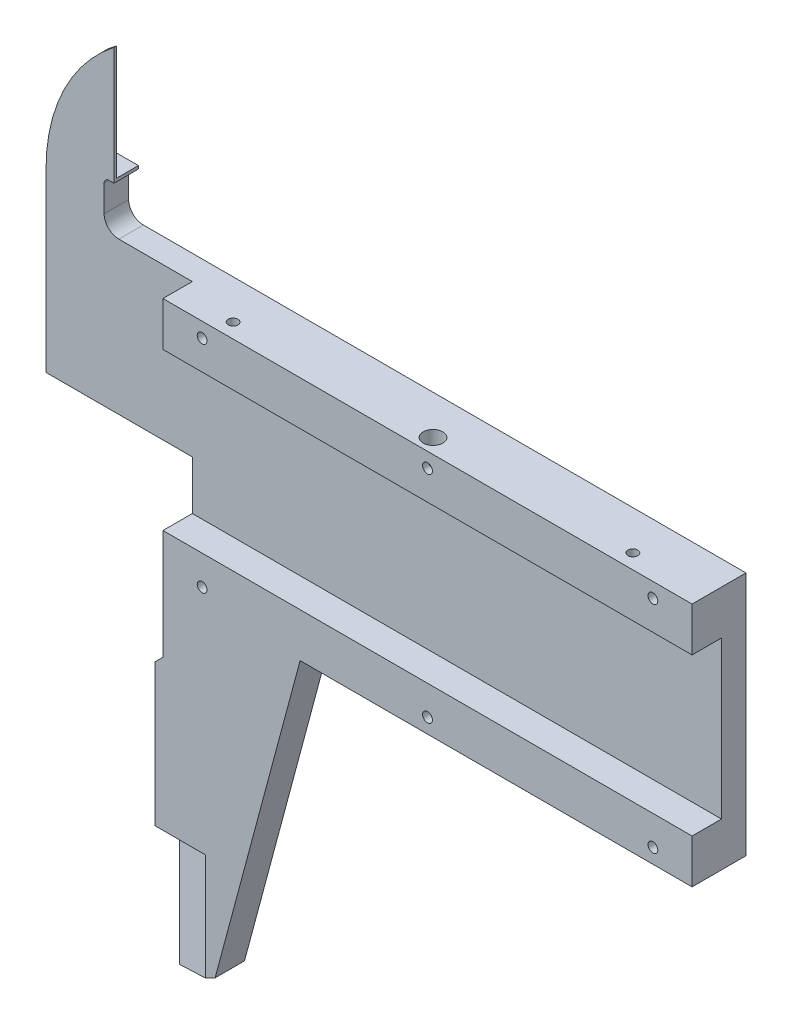
from build123d import *

# Parameters (mm, degrees)
BOSS_EXTRUDE1_DEPTH = 2.75
CUT_EXTRUDE1_DEPTH  = 3
SKETCH3_R           = 0.5
CUT_EXTRUDE2_DEPTH  = 1.25
CUT_EXTRUDE3_START  = 17.5
CUT_EXTRUDE3_DEPTH  = 12.5
SKETCH5_W           = 14.8
SKETCH5_H           = 2.5
CUT_EXTRUDE4_DEPTH  = 36.5
CUT_EXTRUDE5_START  = 35.5
CUT_EXTRUDE5_DEPTH  = 13.5
SKETCH7_R           = 0.5
CUT_EXTRUDE6_DEPTH  = 3
CUT_EXTRUDE7_REACH  = 62.5
SKETCH8_R           = 1


with BuildPart() as part:
    # Sketch1 → Boss-Extrude1 (new body, symmetric)
    with BuildSketch(Plane.XY):
        with BuildLine():
            Line((0, 0), (0, 12.5))
            Line((0, 12.5), (-61.5, 12.5))
            ThreePointArc((-61.5, 12.5), (-62.560660172, 12.939339828), (-63, 14))
            Line((-63, 14), (-63, 16.693487943))
            ThreePointArc((-63, 16.693487943), (-62.853553391, 17.047041334), (-62.5, 17.193487943))
            Line((-62.5, 17.193487943), (-62, 17.193487943))
            Line((-62, 17.193487943), (-62, 29.193487943))
            ThreePointArc((-62, 29.193487943), (-67.10498068, 22.897467949), (-68.93, 15))
            Line((-68.93, 15), (-68.93, -3))
            Line((-68.93, -3), (-54, -3))
            Line((-54, -3), (-54, -19.2))
            Line((-54, -19.2), (-54.8, -20))
            Line((-54.8, -20), (-54.8, -48))
            Line((-54.8, -48), (-48.67612206, -44.87972834))
            Line((-48.67612206, -44.87972834), (-40, -12.5))
            Line((-40, -12.5), (0, -12.5))
            Line((0, -12.5), (0, 0))
        make_face()
    extrude(amount=BOSS_EXTRUDE1_DEPTH, both=True)

    # Sketch2 → Cut-Extrude1 (cut)
    with BuildSketch(Plane.XY.offset(2.75)):
        Polygon((0, -8), (-54, -8), (-84.556927157, -8), (-84.556927157, 35.37162012), (-54, 35.37162012), (-54, 8), (0, 8), align=None)
    extrude(amount=-CUT_EXTRUDE1_DEPTH, mode=Mode.SUBTRACT)

    # Sketch3 → Cut-Extrude2 (cut)
    with BuildSketch(Plane.XY.offset(2.75)):
        with Locations((-4, 11)):
            Circle(SKETCH3_R)
        with Locations((-27, 11)):
            Circle(SKETCH3_R)
        with Locations((-50, 11)):
            Circle(SKETCH3_R)
        with Locations((-50, -11)):
            Circle(SKETCH3_R)
        with Locations((-27, -11)):
            Circle(SKETCH3_R)
        with Locations((-4, -11)):
            Circle(SKETCH3_R)
    extrude(amount=-CUT_EXTRUDE2_DEPTH, mode=Mode.SUBTRACT)

    # Sketch4 → Cut-Extrude3 (cut)
    with BuildSketch(Plane(origin=(0, 12.5, 0), x_dir=(1, 0, 0), z_dir=(0, 1, 0)).offset(CUT_EXTRUDE3_START)):
        Polygon((-68.93, 2.75), (-62, 0.5), (-62, 2.75), align=None)
    extrude(amount=-CUT_EXTRUDE3_DEPTH, mode=Mode.SUBTRACT)

    # Sketch5 → Cut-Extrude4 (cut, through all)
    with BuildSketch(Plane.XZ.offset(12.5)):
        with Locations((-47.4, -1.5)):
            Rectangle(SKETCH5_W, SKETCH5_H)
    extrude(amount=CUT_EXTRUDE4_DEPTH, mode=Mode.SUBTRACT)

    # Sketch6 → Cut-Extrude5 (cut)
    with BuildSketch(Plane.XZ.offset(12.5).offset(CUT_EXTRUDE5_START)):
        Polygon((-54.8, 2.75), (-54.8, 0.25), (-49.674240396, 2.75), align=None)
    extrude(amount=-CUT_EXTRUDE5_DEPTH, mode=Mode.SUBTRACT)

    # Sketch7 → Cut-Extrude6 (cut)
    with BuildSketch(Plane(origin=(0, 12.5, 0), x_dir=(1, 0, 0), z_dir=(0, 1, 0))):
        with Locations((-7.54, -1.25)):
            Circle(SKETCH7_R)
        with Locations((-48.34, -1.25)):
            Circle(SKETCH7_R)
    extrude(amount=-CUT_EXTRUDE6_DEPTH, mode=Mode.SUBTRACT)

    # Sketch8 → Cut-Extrude7 (cut, up to next)
    with BuildSketch(Plane(origin=(0, 12.5, 0), x_dir=(1, 0, 0), z_dir=(0, 1, 0)), mode=Mode.PRIVATE) as cut_extrude7_sk1:
        with Locations((-27.94, -1.25)):
            Circle(SKETCH8_R)
    cut_extrude7_tool1 = extrude(cut_extrude7_sk1.sketch, amount=-CUT_EXTRUDE7_REACH, mode=Mode.PRIVATE) & part.part
    add(cut_extrude7_tool1.solids().sort_by_distance((-27.94, 12.5, 1.25))[0], mode=Mode.SUBTRACT)


solid = part.part
